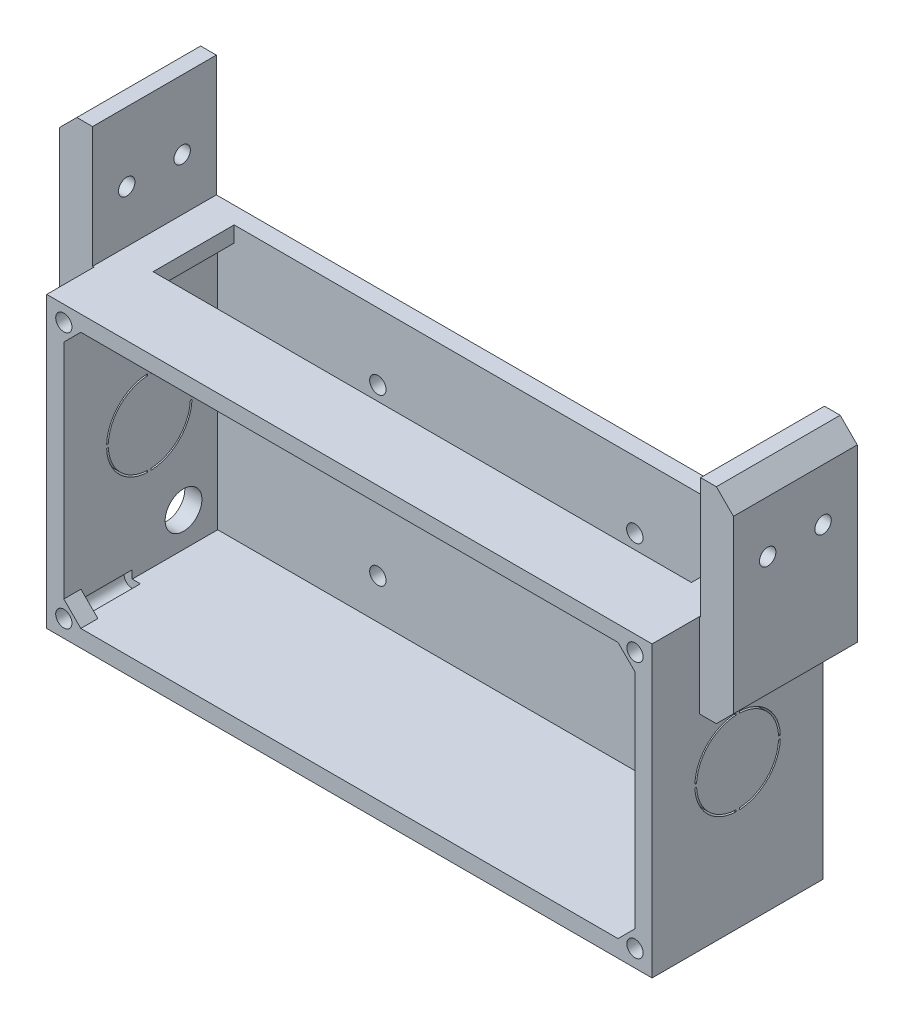
from build123d import *

# Parameters (mm, degrees)
SKETCH1_W           = 177
SKETCH1_H           = 85
BOSS_EXTRUDE1_DEPTH = 50
SHELL1_T            = -5
SKETCH2_W           = 157.4
SKETCH2_H           = 23.7
CUT_EXTRUDE1_DEPTH  = 6
SKETCH4_R           = 5.375
CUT_EXTRUDE2_DEPTH  = 6
SKETCH6_R           = 2.375
BOSS_EXTRUDE3_DEPTH = 5
SKETCH7_R           = 2.375
CUT_EXTRUDE4_DEPTH  = 20
SKETCH8_W           = 10
SKETCH8_H           = 60
BOSS_EXTRUDE4_DEPTH = 36.2
CHAMFER1_SIZE       = 5
SKETCH9_W           = 177.8
SKETCH9_H           = 35.8
SKETCH9_W_2         = 177
SKETCH9_H_2         = 35
CUT_EXTRUDE5_DEPTH  = 51
SKETCH10_R          = 2.4
CUT_EXTRUDE6_DEPTH  = 198
SKETCH11_R          = 2.4
CUT_EXTRUDE8_DEPTH  = 5
CUT_EXTRUDE14_DEPTH = 188


with BuildPart() as part:
    # Sketch1 → Boss-Extrude1 (new body)
    with BuildSketch(Plane.XY):
        Rectangle(SKETCH1_W, SKETCH1_H)
    extrude(amount=BOSS_EXTRUDE1_DEPTH)

    # Shell1
    shell1_openings = [part.faces().sort_by_distance(p)[0] for p in [
        (0, 0, 50),
    ]]
    offset(amount=SHELL1_T, openings=shell1_openings, kind=Kind.INTERSECTION)

    # Sketch2 → Cut-Extrude1 (cut, through all)
    with BuildSketch(Plane.XZ.offset(-37.5)):
        with Locations((0, 16.85)):
            Rectangle(SKETCH2_W, SKETCH2_H)
    extrude(amount=-CUT_EXTRUDE1_DEPTH, mode=Mode.SUBTRACT)

    # Sketch4 → Cut-Extrude2 (cut, through all)
    with BuildSketch(Plane(origin=(-83.5, 0, 0), x_dir=(0, 0, -1), z_dir=(1, 0, 0))):
        with Locations((-15, -27.5)):
            Circle(SKETCH4_R)
    extrude(amount=-CUT_EXTRUDE2_DEPTH, mode=Mode.SUBTRACT)

    # Sketch6 → Boss-Extrude3 (add)
    with BuildSketch(Plane.XY.offset(50)):
        Polygon((87.009300393, 41.009300393), (75.027799397, 41.009300393), (87.009300393, 29.027799397), align=None)
        with Locations((83.5, 37.5)):
            Circle(SKETCH6_R, mode=Mode.SUBTRACT)
        Polygon((75.027799397, -41.009300393), (87.009300393, -29.027799397), (87.009300393, -41.009300393), align=None)
        with Locations((83.5, -37.5)):
            Circle(SKETCH6_R, mode=Mode.SUBTRACT)
        Polygon((-87.009300393, -41.009300393), (-75.027799397, -41.009300393), (-87.009300393, -29.027799397), align=None)
        with Locations((-83.5, -37.5)):
            Circle(SKETCH6_R, mode=Mode.SUBTRACT)
        Polygon((-75.027799397, 41.009300393), (-87.009300393, 29.027799397), (-87.009300393, 41.009300393), align=None)
        with Locations((-83.5, 37.5)):
            Circle(SKETCH6_R, mode=Mode.SUBTRACT)
    extrude(amount=-BOSS_EXTRUDE3_DEPTH)

    # Sketch7 → Cut-Extrude4 (cut)
    with BuildSketch(Plane.XY.offset(50)):
        with Locations((83.5, 37.5)):
            Circle(SKETCH7_R)
        with Locations((83.5, -37.5)):
            Circle(SKETCH7_R)
        with Locations((-83.5, -37.5)):
            Circle(SKETCH7_R)
        with Locations((-83.5, 37.5)):
            Circle(SKETCH7_R)
    extrude(amount=-CUT_EXTRUDE4_DEPTH, mode=Mode.SUBTRACT)

    # Sketch8 → Boss-Extrude4 (add)
    with BuildSketch(Plane(origin=(0, 0, 0), x_dir=(-1, 0, 0), z_dir=(0, 0, -1))):
        with Locations((-93.5, 47.5)):
            Rectangle(SKETCH8_W, SKETCH8_H)
        with Locations((93.5, 47.5)):
            Rectangle(SKETCH8_W, SKETCH8_H)
    extrude(amount=-BOSS_EXTRUDE4_DEPTH)

    # Chamfer1
    chamfer1_edges = [part.edges().sort_by_distance(p)[0] for p in [
        (98.5, 17.5, 18.1),
        (98.5, 77.5, 18.1),
        (-98.5, 77.5, 18.1),
        (-98.5, 17.5, 18.1),
    ]]
    chamfer(chamfer1_edges, length=CHAMFER1_SIZE)

    # Sketch9 → Cut-Extrude5 (cut, through all)
    with BuildSketch(Plane(origin=(0, 0, 0), x_dir=(-1, 0, 0), z_dir=(0, 0, -1))):
        with Locations((0, 60)):
            Rectangle(SKETCH9_W, SKETCH9_H)
        with Locations((0, 60)):
            Rectangle(SKETCH9_W_2, SKETCH9_H_2, mode=Mode.SUBTRACT)
    extrude(amount=-CUT_EXTRUDE5_DEPTH, mode=Mode.SUBTRACT)

    # Sketch10 → Cut-Extrude6 (cut, through all)
    with BuildSketch(Plane(origin=(-98.5, 0, 0), x_dir=(0, 0, -1), z_dir=(1, 0, 0))):
        with Locations((-26.2, 57.3)):
            Circle(SKETCH10_R)
        with Locations((-10, 57.3)):
            Circle(SKETCH10_R)
    extrude(amount=CUT_EXTRUDE6_DEPTH, mode=Mode.SUBTRACT)

    # Sketch11 → Cut-Extrude8 (cut)
    with BuildSketch(Plane.XY.offset(5)):
        with Locations((45.9486, -25.738739303)):
            Circle(SKETCH11_R)
        with Locations((38.4556, 22.597460697)):
            Circle(SKETCH11_R)
        with Locations((-36.6776, 22.597460697)):
            Circle(SKETCH11_R)
        with Locations((-36.6776, -25.738739303)):
            Circle(SKETCH11_R)
    extrude(amount=-CUT_EXTRUDE8_DEPTH, mode=Mode.SUBTRACT)

    # Sketch12 → Cut-Extrude14 (cut, through all)
    with BuildSketch(Plane.ZY.offset(88.5)):
        with BuildLine():
            Line((24.5, 11.789578808), (24.5, 12.289995997))
            ThreePointArc((24.5, 12.289995997), (16.161165235, 8.638834765), (12.510004003, 0.3))
            Line((12.510004003, 0.3), (13.010421192, 0.3))
            ThreePointArc((13.010421192, 0.3), (16.514718626, 8.285281374), (24.5, 11.789578808))
        make_face()
        with BuildLine():
            Line((13.010421192, -0.7), (12.510004003, -0.7))
            ThreePointArc((12.510004003, -0.7), (16.161165235, -9.038834765), (24.5, -12.689995997))
            Line((24.5, -12.689995997), (24.5, -12.189578808))
            ThreePointArc((24.5, -12.189578808), (16.514718626, -8.685281374), (13.010421192, -0.7))
        make_face()
        with BuildLine():
            Line((37.489995997, -0.7), (36.989578808, -0.7))
            ThreePointArc((36.989578808, -0.7), (33.485281374, -8.685281374), (25.5, -12.189578808))
            Line((25.5, -12.189578808), (25.5, -12.689995997))
            ThreePointArc((25.5, -12.689995997), (33.838834765, -9.038834765), (37.489995997, -0.7))
        make_face()
        with BuildLine():
            ThreePointArc((37.489995997, 0.3), (33.838834765, 8.638834765), (25.5, 12.289995997))
            Line((25.5, 12.289995997), (25.5, 11.789578808))
            ThreePointArc((25.5, 11.789578808), (33.485281374, 8.285281374), (36.989578808, 0.3))
            Line((36.989578808, 0.3), (37.489995997, 0.3))
        make_face()
    extrude(amount=-CUT_EXTRUDE14_DEPTH, mode=Mode.SUBTRACT)


solid = part.part
